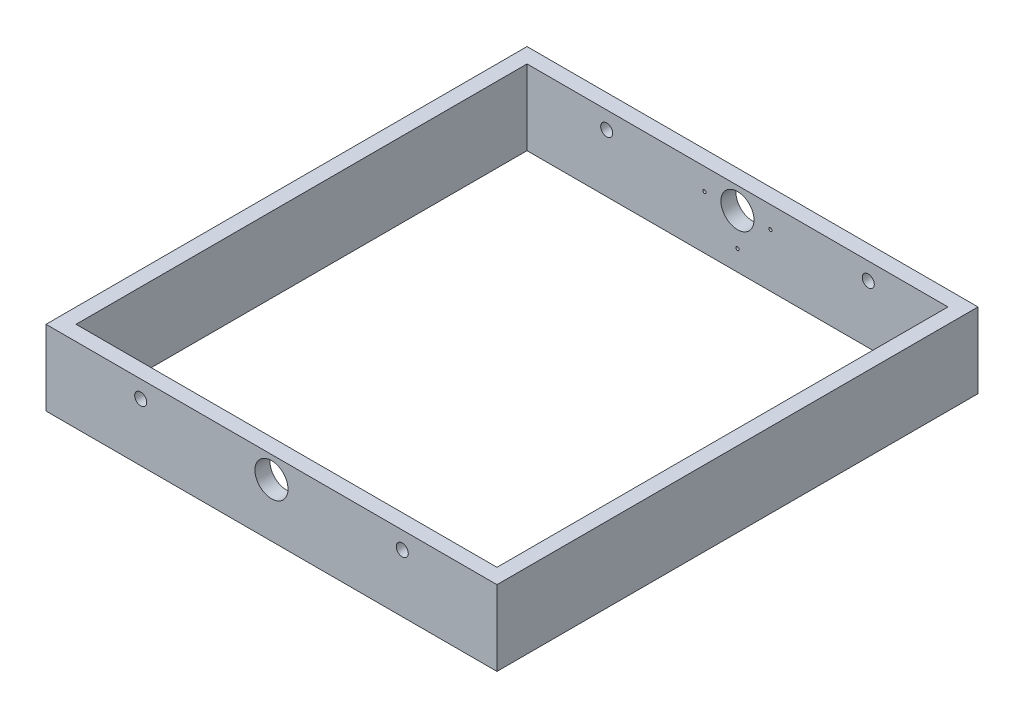
from build123d import *

# Parameters (mm, degrees)
CROQUIS1_W              = 300
CROQUIS1_H              = 320
CROQUIS1_W_2            = 280
CROQUIS1_H_2            = 300
SALIENTE_EXTRUIR1_DEPTH = 50
CROQUIS2_R              = 4
CROQUIS2_R_2            = 11
CORTAR_EXTRUIR1_DEPTH   = 321
SKETCH1_R               = 1.09
CUT_EXTRUDE1_DEPTH      = 10


with BuildPart() as part:
    # Croquis1 → Saliente-Extruir1 (new body)
    with BuildSketch(Plane(origin=(0, 0, 0), x_dir=(1, 0, 0), z_dir=(0, 1, 0))):
        Rectangle(CROQUIS1_W, CROQUIS1_H)
        Rectangle(CROQUIS1_W_2, CROQUIS1_H_2, mode=Mode.SUBTRACT)
    extrude(amount=SALIENTE_EXTRUIR1_DEPTH)

    # Croquis2 → Cortar-Extruir1 (cut, through all)
    with BuildSketch(Plane.XY.offset(160)):
        with Locations((-87, 38.5)):
            Circle(CROQUIS2_R)
        with Locations((0, 35.5)):
            Circle(CROQUIS2_R_2)
        with Locations((87, 38.5)):
            Circle(CROQUIS2_R)
    extrude(amount=-CORTAR_EXTRUIR1_DEPTH, mode=Mode.SUBTRACT)

    # Sketch1 → Cut-Extrude1 (cut)
    with BuildSketch(Plane(origin=(0, 0, -160), x_dir=(-1, 0, 0), z_dir=(0, 0, -1))):
        with Locations((0, 13.579689783)):
            Circle(SKETCH1_R)
        with Locations((-21.920310217, 35.5)):
            Circle(SKETCH1_R)
        with Locations((21.920310217, 35.5)):
            Circle(SKETCH1_R)
    extrude(amount=-CUT_EXTRUDE1_DEPTH, mode=Mode.SUBTRACT)


solid = part.part
